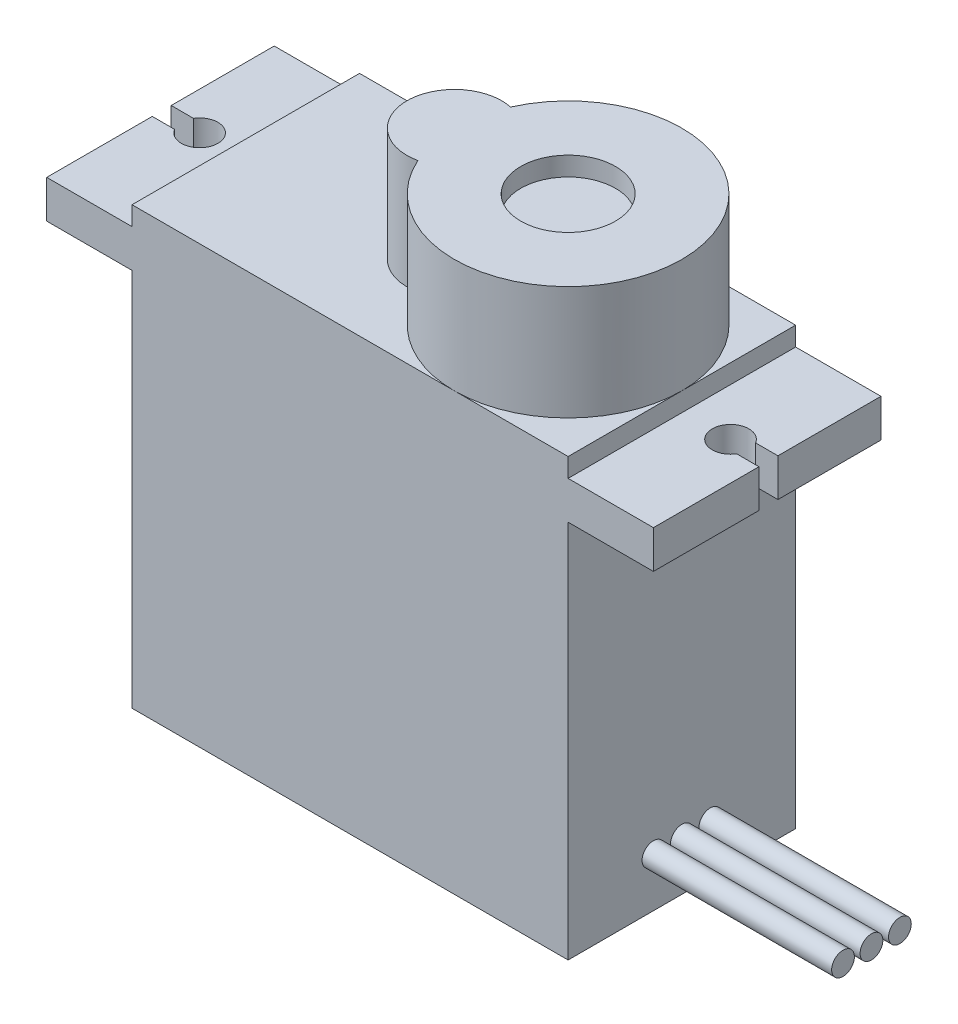
from build123d import *

# Parameters (mm, degrees)
EXTRUDE_1_DEPTH     = 12
EXTRUDE_2_DEPTH     = 6
CUT_EXTRUDE_1_DEPTH = 5
SKETCH_6_R          = 0.6
EXTRUDE_5_DEPTH     = 10
SKETCH_3_R          = 2.5
CUT_EXTRUDE_2_DEPTH = 1


with BuildPart() as part:
    # 草图1 → 凸台-拉伸1 (new body)
    with BuildSketch(Plane.XY):
        Polygon((-11.5, 11.5), (11.5, 11.5), (11.5, 10.5), (16, 10.5), (16, 8.5), (11.5, 8.5), (11.5, -11.5), (-11.5, -11.5), (-11.5, 8.5), (-16, 8.5), (-16, 10.5), (-11.5, 10.5), align=None)
    extrude(amount=EXTRUDE_1_DEPTH)

    # 草图2 → 凸台-拉伸2 (add)
    with BuildSketch(Plane(origin=(0, 11.5, 0), x_dir=(1, 0, 0), z_dir=(0, 1, 0))):
        with BuildLine():
            ThreePointArc((0.020833333, -8.445144707), (11.5, -6), (0.020833333, -3.554855293))
            ThreePointArc((0.020833333, -3.554855293), (-3, -6), (0.020833333, -8.445144707))
        make_face()
    extrude(amount=EXTRUDE_2_DEPTH)

    # 草图4 → 切除-拉伸1 (cut)
    with BuildSketch(Plane(origin=(0, 10.5, 0), x_dir=(1, 0, 0), z_dir=(0, 1, 0))):
        with BuildLine():
            Line((16, -5.433355599), (14.823962452, -5.433355599))
            ThreePointArc((14.823962452, -5.433355599), (13.036198089, -5.933355599), (14.823962452, -6.433355599))
            Line((14.823962452, -6.433355599), (16, -6.433355599))
            Line((16, -6.433355599), (16, -5.433355599))
        make_face()
        with BuildLine():
            Line((-16, -5.433355599), (-14.823962452, -5.433355599))
            ThreePointArc((-14.823962452, -5.433355599), (-13.036198089, -5.933355599), (-14.823962452, -6.433355599))
            Line((-14.823962452, -6.433355599), (-16, -6.433355599))
            Line((-16, -6.433355599), (-16, -5.433355599))
        make_face()
    extrude(amount=-CUT_EXTRUDE_1_DEPTH, mode=Mode.SUBTRACT)

    # 草图6 → 凸台-拉伸5 (add)
    with BuildSketch(Plane(origin=(11.5, 0, 0), x_dir=(0, 0, -1), z_dir=(1, 0, 0))):
        with Locations((-6, -8.9)):
            Circle(SKETCH_6_R)
        with Locations((-7.5, -8.9)):
            Circle(SKETCH_6_R)
        with Locations((-4.5, -8.9)):
            Circle(SKETCH_6_R)
    extrude(amount=EXTRUDE_5_DEPTH)

    # 草图3 → 切除-拉伸2 (cut)
    with BuildSketch(Plane(origin=(0, 17.5, 0), x_dir=(1, 0, 0), z_dir=(0, 1, 0))):
        with Locations((5.5, -6)):
            Circle(SKETCH_3_R)
    extrude(amount=-CUT_EXTRUDE_2_DEPTH, mode=Mode.SUBTRACT)


solid = part.part
